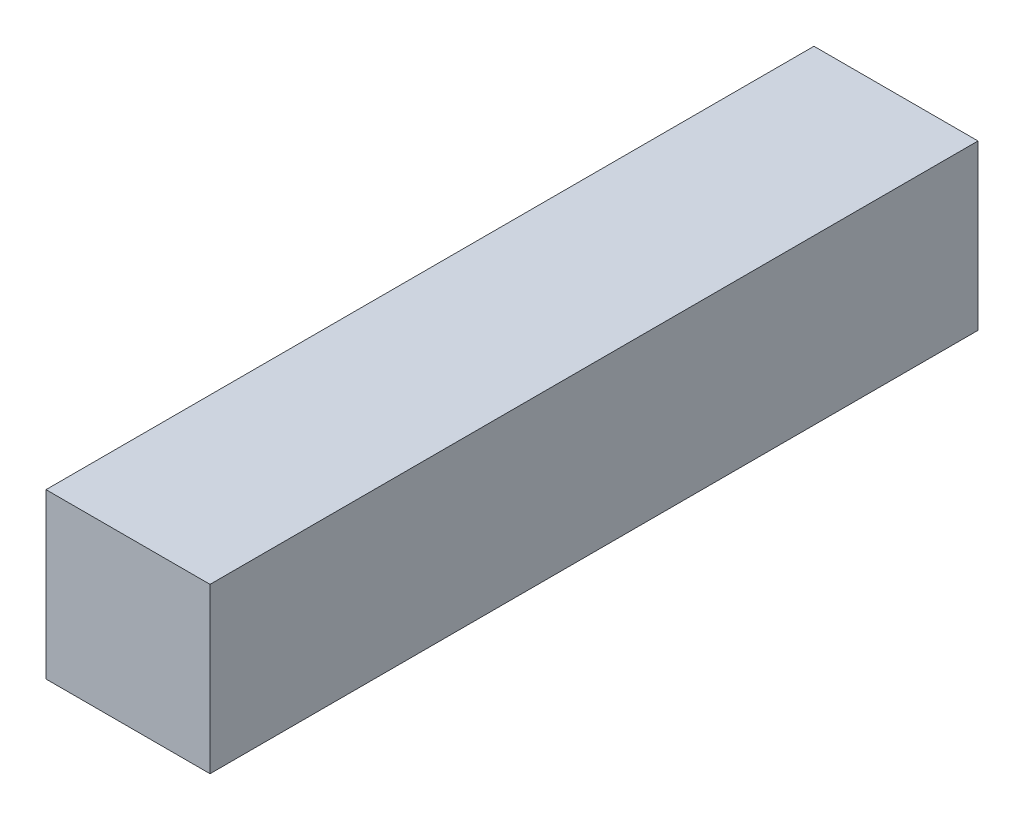
from build123d import *

# Parameters (mm, degrees)
ESQUISSE1_W      = 22
ESQUISSE1_H      = 22
EXTRUSION1_DEPTH = 103


with BuildPart() as part:
    # Esquisse1 → Extrusion1 (new body)
    with BuildSketch(Plane.XY):
        with Locations((11, 11)):
            Rectangle(ESQUISSE1_W, ESQUISSE1_H)
    extrude(amount=-EXTRUSION1_DEPTH)


solid = part.part
